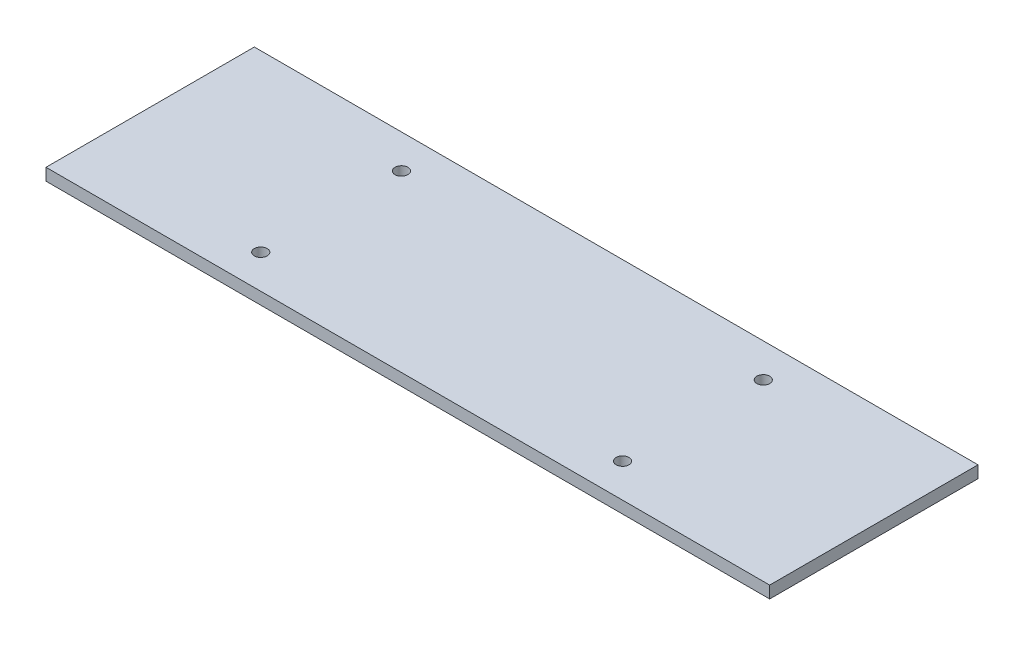
from build123d import *

# Parameters (mm, degrees)
SKETCH1_W           = 180
SKETCH1_H           = 51.82
BOSS_EXTRUDE1_DEPTH = 3
SKETCH2_R           = 1.6
HOODBOARD_DEPTH     = 4


with BuildPart() as part:
    # Sketch1 → Boss-Extrude1 (new body)
    with BuildSketch(Plane(origin=(0, 0, 0), x_dir=(1, 0, 0), z_dir=(0, 1, 0))):
        with Locations((26.592178535, 0.716303675)):
            Rectangle(SKETCH1_W, SKETCH1_H)
    extrude(amount=BOSS_EXTRUDE1_DEPTH)

    # Sketch2 → HoodBoard (cut, through all)
    with BuildSketch(Plane(origin=(0, 3, 0), x_dir=(1, 0, 0), z_dir=(0, 1, 0))):
        with Locations((-18.407821465, 18.216303675)):
            Circle(SKETCH2_R)
        with Locations((71.592178535, 18.216303675)):
            Circle(SKETCH2_R)
        with Locations((71.592178535, -16.783696325)):
            Circle(SKETCH2_R)
        with Locations((-18.407821465, -16.783696325)):
            Circle(SKETCH2_R)
    extrude(amount=-HOODBOARD_DEPTH, mode=Mode.SUBTRACT)


solid = part.part
